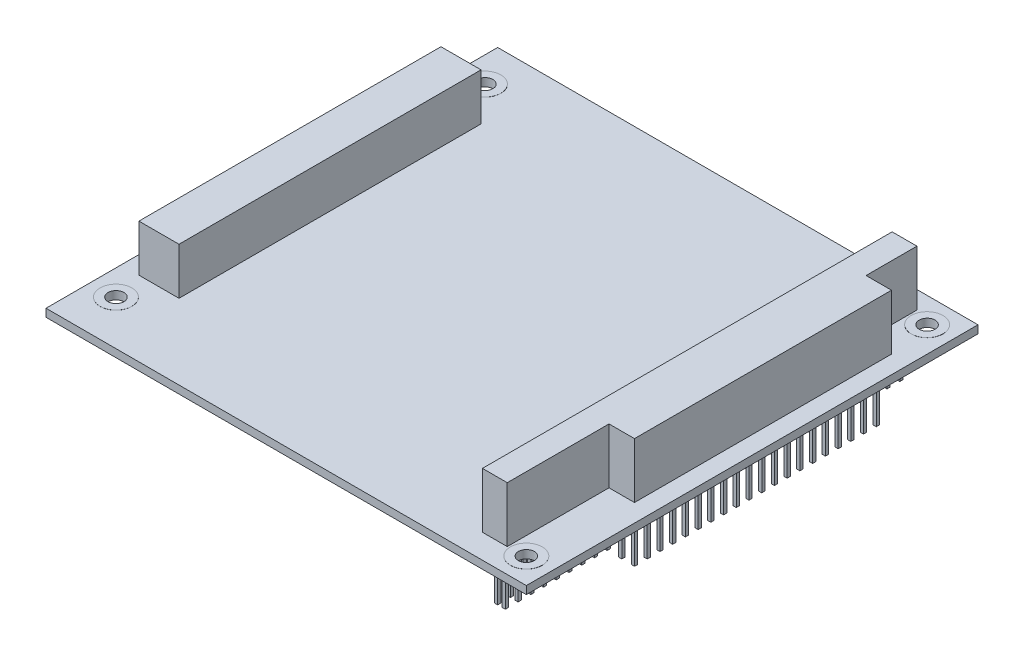
from build123d import *

# Parameters (mm, degrees)
SKETCH1_W                  = 95.89
SKETCH1_H                  = 90.17
BASE_EXTRUDE_DEPTH         = 1.57
SKETCH2_R                  = 1.59
MOUNTING_HOLES_DEPTH       = 66.831946272
SKETCH3_R                  = 3.175
SKETCH3_R_2                = 1.59
TOP_PADS_DEPTH             = 0.02
SKETCH4_R                  = 3.175
SKETCH4_R_2                = 1.59
BOTT_PADS_DEPTH            = 0.02
ISA_CNCT_DEPTH             = 11.05
SKETCH6_W                  = 8
SKETCH6_H                  = 60.3
PCI_CNCT_DEPTH             = 9.35
SKETCH7_W                  = 11.3
SKETCH7_H                  = 63.35
SKETCH7_W_2                = 8.51
SKETCH7_H_2                = 60.96
PCI_CNCT_SHROUD_DEPTH      = 11.18
SKETCH8_W                  = 0.64
SKETCH8_H                  = 0.64
BOT_ISA_DEPTH              = 10.67
LPATTERN1_COUNT            = 32
LPATTERN1_PITCH            = 2.54
SKETCH9_W                  = 0.64
SKETCH9_H                  = 0.64
BOSS_EXTRUDE7_DEPTH        = 10.67
LPATTERN2_COUNT            = 20
LPATTERN2_PITCH            = 2.54
SKETCH10_W                 = 0.5
SKETCH10_H                 = 0.5
PCI_BASE_DEPTH             = 10.41
LPATTERN3_COUNT            = 30
LPATTERN3_PITCH            = 2
LPATTERN4_COUNT            = 4
LPATTERN4_PITCH            = 2
LPATTERN4_COPY_1_SKETCH_W  = 0.5
LPATTERN4_COPY_1_SKETCH_H  = 0.5
LPATTERN4_COPY_1_DEPTH     = 10.41
LPATTERN4_COPY_2_SKETCH_W  = 0.5
LPATTERN4_COPY_2_SKETCH_H  = 0.5
LPATTERN4_COPY_2_DEPTH     = 10.41
LPATTERN4_COPY_3_SKETCH_W  = 0.5
LPATTERN4_COPY_3_SKETCH_H  = 0.5
LPATTERN4_COPY_3_DEPTH     = 10.41
LPATTERN4_COPY_4_SKETCH_W  = 0.5
LPATTERN4_COPY_4_SKETCH_H  = 0.5
LPATTERN4_COPY_4_DEPTH     = 10.41
LPATTERN4_COPY_5_SKETCH_W  = 0.5
LPATTERN4_COPY_5_SKETCH_H  = 0.5
LPATTERN4_COPY_5_DEPTH     = 10.41
LPATTERN4_COPY_6_SKETCH_W  = 0.5
LPATTERN4_COPY_6_SKETCH_H  = 0.5
LPATTERN4_COPY_6_DEPTH     = 10.41
LPATTERN4_COPY_7_SKETCH_W  = 0.5
LPATTERN4_COPY_7_SKETCH_H  = 0.5
LPATTERN4_COPY_7_DEPTH     = 10.41
LPATTERN4_COPY_8_SKETCH_W  = 0.5
LPATTERN4_COPY_8_SKETCH_H  = 0.5
LPATTERN4_COPY_8_DEPTH     = 10.41
LPATTERN4_COPY_9_SKETCH_W  = 0.5
LPATTERN4_COPY_9_SKETCH_H  = 0.5
LPATTERN4_COPY_9_DEPTH     = 10.41
LPATTERN4_COPY_10_SKETCH_W = 0.5
LPATTERN4_COPY_10_SKETCH_H = 0.5
LPATTERN4_COPY_10_DEPTH    = 10.41
LPATTERN4_COPY_11_SKETCH_W = 0.5
LPATTERN4_COPY_11_SKETCH_H = 0.5
LPATTERN4_COPY_11_DEPTH    = 10.41
LPATTERN4_COPY_12_SKETCH_W = 0.5
LPATTERN4_COPY_12_SKETCH_H = 0.5
LPATTERN4_COPY_12_DEPTH    = 10.41
LPATTERN4_COPY_13_SKETCH_W = 0.5
LPATTERN4_COPY_13_SKETCH_H = 0.5
LPATTERN4_COPY_13_DEPTH    = 10.41
LPATTERN4_COPY_14_SKETCH_W = 0.5
LPATTERN4_COPY_14_SKETCH_H = 0.5
LPATTERN4_COPY_14_DEPTH    = 10.41
LPATTERN4_COPY_15_SKETCH_W = 0.5
LPATTERN4_COPY_15_SKETCH_H = 0.5
LPATTERN4_COPY_15_DEPTH    = 10.41
LPATTERN4_COPY_16_SKETCH_W = 0.5
LPATTERN4_COPY_16_SKETCH_H = 0.5
LPATTERN4_COPY_16_DEPTH    = 10.41
LPATTERN4_COPY_17_SKETCH_W = 0.5
LPATTERN4_COPY_17_SKETCH_H = 0.5
LPATTERN4_COPY_17_DEPTH    = 10.41
LPATTERN4_COPY_18_SKETCH_W = 0.5
LPATTERN4_COPY_18_SKETCH_H = 0.5
LPATTERN4_COPY_18_DEPTH    = 10.41
LPATTERN4_COPY_19_SKETCH_W = 0.5
LPATTERN4_COPY_19_SKETCH_H = 0.5
LPATTERN4_COPY_19_DEPTH    = 10.41
LPATTERN4_COPY_20_SKETCH_W = 0.5
LPATTERN4_COPY_20_SKETCH_H = 0.5
LPATTERN4_COPY_20_DEPTH    = 10.41
LPATTERN4_COPY_21_SKETCH_W = 0.5
LPATTERN4_COPY_21_SKETCH_H = 0.5
LPATTERN4_COPY_21_DEPTH    = 10.41
LPATTERN4_COPY_22_SKETCH_W = 0.5
LPATTERN4_COPY_22_SKETCH_H = 0.5
LPATTERN4_COPY_22_DEPTH    = 10.41
LPATTERN4_COPY_23_SKETCH_W = 0.5
LPATTERN4_COPY_23_SKETCH_H = 0.5
LPATTERN4_COPY_23_DEPTH    = 10.41
LPATTERN4_COPY_24_SKETCH_W = 0.5
LPATTERN4_COPY_24_SKETCH_H = 0.5
LPATTERN4_COPY_24_DEPTH    = 10.41
LPATTERN4_COPY_25_SKETCH_W = 0.5
LPATTERN4_COPY_25_SKETCH_H = 0.5
LPATTERN4_COPY_25_DEPTH    = 10.41
LPATTERN4_COPY_26_SKETCH_W = 0.5
LPATTERN4_COPY_26_SKETCH_H = 0.5
LPATTERN4_COPY_26_DEPTH    = 10.41
LPATTERN4_COPY_27_SKETCH_W = 0.5
LPATTERN4_COPY_27_SKETCH_H = 0.5
LPATTERN4_COPY_27_DEPTH    = 10.41
LPATTERN4_COPY_28_SKETCH_W = 0.5
LPATTERN4_COPY_28_SKETCH_H = 0.5
LPATTERN4_COPY_28_DEPTH    = 10.41
LPATTERN4_COPY_29_SKETCH_W = 0.5
LPATTERN4_COPY_29_SKETCH_H = 0.5
LPATTERN4_COPY_29_DEPTH    = 10.41
LPATTERN4_COPY_30_SKETCH_W = 0.5
LPATTERN4_COPY_30_SKETCH_H = 0.5
LPATTERN4_COPY_30_DEPTH    = 10.41
LPATTERN4_COPY_31_SKETCH_W = 0.5
LPATTERN4_COPY_31_SKETCH_H = 0.5
LPATTERN4_COPY_31_DEPTH    = 10.41
LPATTERN4_COPY_32_SKETCH_W = 0.5
LPATTERN4_COPY_32_SKETCH_H = 0.5
LPATTERN4_COPY_32_DEPTH    = 10.41
LPATTERN4_COPY_33_SKETCH_W = 0.5
LPATTERN4_COPY_33_SKETCH_H = 0.5
LPATTERN4_COPY_33_DEPTH    = 10.41
LPATTERN4_COPY_34_SKETCH_W = 0.5
LPATTERN4_COPY_34_SKETCH_H = 0.5
LPATTERN4_COPY_34_DEPTH    = 10.41
LPATTERN4_COPY_35_SKETCH_W = 0.5
LPATTERN4_COPY_35_SKETCH_H = 0.5
LPATTERN4_COPY_35_DEPTH    = 10.41
LPATTERN4_COPY_36_SKETCH_W = 0.5
LPATTERN4_COPY_36_SKETCH_H = 0.5
LPATTERN4_COPY_36_DEPTH    = 10.41
LPATTERN4_COPY_37_SKETCH_W = 0.5
LPATTERN4_COPY_37_SKETCH_H = 0.5
LPATTERN4_COPY_37_DEPTH    = 10.41
LPATTERN4_COPY_38_SKETCH_W = 0.5
LPATTERN4_COPY_38_SKETCH_H = 0.5
LPATTERN4_COPY_38_DEPTH    = 10.41
LPATTERN4_COPY_39_SKETCH_W = 0.5
LPATTERN4_COPY_39_SKETCH_H = 0.5
LPATTERN4_COPY_39_DEPTH    = 10.41
LPATTERN4_COPY_40_SKETCH_W = 0.5
LPATTERN4_COPY_40_SKETCH_H = 0.5
LPATTERN4_COPY_40_DEPTH    = 10.41
LPATTERN4_COPY_41_SKETCH_W = 0.5
LPATTERN4_COPY_41_SKETCH_H = 0.5
LPATTERN4_COPY_41_DEPTH    = 10.41
LPATTERN4_COPY_42_SKETCH_W = 0.5
LPATTERN4_COPY_42_SKETCH_H = 0.5
LPATTERN4_COPY_42_DEPTH    = 10.41
LPATTERN4_COPY_43_SKETCH_W = 0.5
LPATTERN4_COPY_43_SKETCH_H = 0.5
LPATTERN4_COPY_43_DEPTH    = 10.41
LPATTERN4_COPY_44_SKETCH_W = 0.5
LPATTERN4_COPY_44_SKETCH_H = 0.5
LPATTERN4_COPY_44_DEPTH    = 10.41
LPATTERN4_COPY_45_SKETCH_W = 0.5
LPATTERN4_COPY_45_SKETCH_H = 0.5
LPATTERN4_COPY_45_DEPTH    = 10.41
LPATTERN4_COPY_46_SKETCH_W = 0.5
LPATTERN4_COPY_46_SKETCH_H = 0.5
LPATTERN4_COPY_46_DEPTH    = 10.41
LPATTERN4_COPY_47_SKETCH_W = 0.5
LPATTERN4_COPY_47_SKETCH_H = 0.5
LPATTERN4_COPY_47_DEPTH    = 10.41
LPATTERN4_COPY_48_SKETCH_W = 0.5
LPATTERN4_COPY_48_SKETCH_H = 0.5
LPATTERN4_COPY_48_DEPTH    = 10.41
LPATTERN4_COPY_49_SKETCH_W = 0.5
LPATTERN4_COPY_49_SKETCH_H = 0.5
LPATTERN4_COPY_49_DEPTH    = 10.41
LPATTERN4_COPY_50_SKETCH_W = 0.5
LPATTERN4_COPY_50_SKETCH_H = 0.5
LPATTERN4_COPY_50_DEPTH    = 10.41
LPATTERN4_COPY_51_SKETCH_W = 0.5
LPATTERN4_COPY_51_SKETCH_H = 0.5
LPATTERN4_COPY_51_DEPTH    = 10.41
LPATTERN4_COPY_52_SKETCH_W = 0.5
LPATTERN4_COPY_52_SKETCH_H = 0.5
LPATTERN4_COPY_52_DEPTH    = 10.41
LPATTERN4_COPY_53_SKETCH_W = 0.5
LPATTERN4_COPY_53_SKETCH_H = 0.5
LPATTERN4_COPY_53_DEPTH    = 10.41
LPATTERN4_COPY_54_SKETCH_W = 0.5
LPATTERN4_COPY_54_SKETCH_H = 0.5
LPATTERN4_COPY_54_DEPTH    = 10.41
LPATTERN4_COPY_55_SKETCH_W = 0.5
LPATTERN4_COPY_55_SKETCH_H = 0.5
LPATTERN4_COPY_55_DEPTH    = 10.41
LPATTERN4_COPY_56_SKETCH_W = 0.5
LPATTERN4_COPY_56_SKETCH_H = 0.5
LPATTERN4_COPY_56_DEPTH    = 10.41
LPATTERN4_COPY_57_SKETCH_W = 0.5
LPATTERN4_COPY_57_SKETCH_H = 0.5
LPATTERN4_COPY_57_DEPTH    = 10.41
LPATTERN4_COPY_58_SKETCH_W = 0.5
LPATTERN4_COPY_58_SKETCH_H = 0.5
LPATTERN4_COPY_58_DEPTH    = 10.41
LPATTERN4_COPY_59_SKETCH_W = 0.5
LPATTERN4_COPY_59_SKETCH_H = 0.5
LPATTERN4_COPY_59_DEPTH    = 10.41
LPATTERN4_COPY_60_SKETCH_W = 0.5
LPATTERN4_COPY_60_SKETCH_H = 0.5
LPATTERN4_COPY_60_DEPTH    = 10.41
LPATTERN4_COPY_61_SKETCH_W = 0.5
LPATTERN4_COPY_61_SKETCH_H = 0.5
LPATTERN4_COPY_61_DEPTH    = 10.41
LPATTERN4_COPY_62_SKETCH_W = 0.5
LPATTERN4_COPY_62_SKETCH_H = 0.5
LPATTERN4_COPY_62_DEPTH    = 10.41
LPATTERN4_COPY_63_SKETCH_W = 0.5
LPATTERN4_COPY_63_SKETCH_H = 0.5
LPATTERN4_COPY_63_DEPTH    = 10.41
LPATTERN4_COPY_64_SKETCH_W = 0.5
LPATTERN4_COPY_64_SKETCH_H = 0.5
LPATTERN4_COPY_64_DEPTH    = 10.41
LPATTERN4_COPY_65_SKETCH_W = 0.5
LPATTERN4_COPY_65_SKETCH_H = 0.5
LPATTERN4_COPY_65_DEPTH    = 10.41
LPATTERN4_COPY_66_SKETCH_W = 0.5
LPATTERN4_COPY_66_SKETCH_H = 0.5
LPATTERN4_COPY_66_DEPTH    = 10.41
LPATTERN4_COPY_67_SKETCH_W = 0.5
LPATTERN4_COPY_67_SKETCH_H = 0.5
LPATTERN4_COPY_67_DEPTH    = 10.41
LPATTERN4_COPY_68_SKETCH_W = 0.5
LPATTERN4_COPY_68_SKETCH_H = 0.5
LPATTERN4_COPY_68_DEPTH    = 10.41
LPATTERN4_COPY_69_SKETCH_W = 0.5
LPATTERN4_COPY_69_SKETCH_H = 0.5
LPATTERN4_COPY_69_DEPTH    = 10.41
LPATTERN4_COPY_70_SKETCH_W = 0.5
LPATTERN4_COPY_70_SKETCH_H = 0.5
LPATTERN4_COPY_70_DEPTH    = 10.41
LPATTERN4_COPY_71_SKETCH_W = 0.5
LPATTERN4_COPY_71_SKETCH_H = 0.5
LPATTERN4_COPY_71_DEPTH    = 10.41
LPATTERN4_COPY_72_SKETCH_W = 0.5
LPATTERN4_COPY_72_SKETCH_H = 0.5
LPATTERN4_COPY_72_DEPTH    = 10.41
LPATTERN4_COPY_73_SKETCH_W = 0.5
LPATTERN4_COPY_73_SKETCH_H = 0.5
LPATTERN4_COPY_73_DEPTH    = 10.41
LPATTERN4_COPY_74_SKETCH_W = 0.5
LPATTERN4_COPY_74_SKETCH_H = 0.5
LPATTERN4_COPY_74_DEPTH    = 10.41
LPATTERN4_COPY_75_SKETCH_W = 0.5
LPATTERN4_COPY_75_SKETCH_H = 0.5
LPATTERN4_COPY_75_DEPTH    = 10.41
LPATTERN4_COPY_76_SKETCH_W = 0.5
LPATTERN4_COPY_76_SKETCH_H = 0.5
LPATTERN4_COPY_76_DEPTH    = 10.41
LPATTERN4_COPY_77_SKETCH_W = 0.5
LPATTERN4_COPY_77_SKETCH_H = 0.5
LPATTERN4_COPY_77_DEPTH    = 10.41
LPATTERN4_COPY_78_SKETCH_W = 0.5
LPATTERN4_COPY_78_SKETCH_H = 0.5
LPATTERN4_COPY_78_DEPTH    = 10.41
LPATTERN4_COPY_79_SKETCH_W = 0.5
LPATTERN4_COPY_79_SKETCH_H = 0.5
LPATTERN4_COPY_79_DEPTH    = 10.41
LPATTERN4_COPY_80_SKETCH_W = 0.5
LPATTERN4_COPY_80_SKETCH_H = 0.5
LPATTERN4_COPY_80_DEPTH    = 10.41
LPATTERN4_COPY_81_SKETCH_W = 0.5
LPATTERN4_COPY_81_SKETCH_H = 0.5
LPATTERN4_COPY_81_DEPTH    = 10.41
LPATTERN4_COPY_82_SKETCH_W = 0.5
LPATTERN4_COPY_82_SKETCH_H = 0.5
LPATTERN4_COPY_82_DEPTH    = 10.41
LPATTERN4_COPY_83_SKETCH_W = 0.5
LPATTERN4_COPY_83_SKETCH_H = 0.5
LPATTERN4_COPY_83_DEPTH    = 10.41
LPATTERN4_COPY_84_SKETCH_W = 0.5
LPATTERN4_COPY_84_SKETCH_H = 0.5
LPATTERN4_COPY_84_DEPTH    = 10.41
LPATTERN4_COPY_85_SKETCH_W = 0.5
LPATTERN4_COPY_85_SKETCH_H = 0.5
LPATTERN4_COPY_85_DEPTH    = 10.41
LPATTERN4_COPY_86_SKETCH_W = 0.5
LPATTERN4_COPY_86_SKETCH_H = 0.5
LPATTERN4_COPY_86_DEPTH    = 10.41
LPATTERN4_COPY_87_SKETCH_W = 0.5
LPATTERN4_COPY_87_SKETCH_H = 0.5
LPATTERN4_COPY_87_DEPTH    = 10.41


with BuildPart() as part:
    # Sketch1 → Base-Extrude (new body)
    with BuildSketch(Plane(origin=(0, 0, 0), x_dir=(1, 0, 0), z_dir=(0, 1, 0))):
        Rectangle(SKETCH1_W, SKETCH1_H)
    extrude(amount=BASE_EXTRUDE_DEPTH)

    # Sketch2 → Mounting Holes (cut, through all)
    with BuildSketch(Plane(origin=(0, 1.57, 0), x_dir=(-1, 0, 0), z_dir=(0, 1, 0))):
        with Locations(Location((42.865, -37.465, 0), (0, 0, 90))):
            Circle(SKETCH2_R)
        with Locations(Location((42.865, 36.195, 0), (0, 0, 90))):
            Circle(SKETCH2_R)
        with Locations(Location((-42.865, 40.005, 0), (0, 0, 90))):
            Circle(SKETCH2_R)
        with Locations(Location((-42.865, -40.005, 0), (0, 0, 90))):
            Circle(SKETCH2_R)
    extrude(amount=-MOUNTING_HOLES_DEPTH, mode=Mode.SUBTRACT)

    # Sketch3 → Top Pads (add)
    with BuildSketch(Plane(origin=(0, 1.57, 0), x_dir=(-1, 0, 0), z_dir=(0, 1, 0))):
        with Locations(Location((42.865, -37.465, 0), (0, 0, 270))):
            Circle(SKETCH3_R)
        with Locations(Location((42.865, -37.465, 0), (0, 0, 90))):
            Circle(SKETCH3_R_2, mode=Mode.SUBTRACT)
        with Locations(Location((-42.865, -40.005, 0), (0, 0, 270))):
            Circle(SKETCH3_R)
        with Locations(Location((-42.865, -40.005, 0), (0, 0, 90))):
            Circle(SKETCH3_R_2, mode=Mode.SUBTRACT)
        with Locations(Location((-42.865, 40.005, 0), (0, 0, 270))):
            Circle(SKETCH3_R)
        with Locations(Location((-42.865, 40.005, 0), (0, 0, 90))):
            Circle(SKETCH3_R_2, mode=Mode.SUBTRACT)
        with Locations(Location((42.865, 36.195, 0), (0, 0, 270))):
            Circle(SKETCH3_R)
        with Locations(Location((42.865, 36.195, 0), (0, 0, 90))):
            Circle(SKETCH3_R_2, mode=Mode.SUBTRACT)
    extrude(amount=TOP_PADS_DEPTH)

    # Sketch4 → Bott Pads (add)
    with BuildSketch(Plane.XZ):
        with Locations(Location((-42.865, -37.465, 0), (0, 0, 270))):
            Circle(SKETCH4_R)
        with Locations(Location((-42.865, -37.465, 0), (0, 0, 90))):
            Circle(SKETCH4_R_2, mode=Mode.SUBTRACT)
        with Locations(Location((42.865, -40.005, 0), (0, 0, 270))):
            Circle(SKETCH4_R)
        with Locations(Location((42.865, -40.005, 0), (0, 0, 90))):
            Circle(SKETCH4_R_2, mode=Mode.SUBTRACT)
        with Locations(Location((42.865, 40.005, 0), (0, 0, 270))):
            Circle(SKETCH4_R)
        with Locations(Location((42.865, 40.005, 0), (0, 0, 90))):
            Circle(SKETCH4_R_2, mode=Mode.SUBTRACT)
        with Locations(Location((-42.865, 36.195, 0), (0, 0, 270))):
            Circle(SKETCH4_R)
        with Locations(Location((-42.865, 36.195, 0), (0, 0, 90))):
            Circle(SKETCH4_R_2, mode=Mode.SUBTRACT)
    extrude(amount=BOTT_PADS_DEPTH)

    # Sketch5 → ISA Cnct (add)
    with BuildSketch(Plane(origin=(0, 1.57, 0), x_dir=(-1, 0, 0), z_dir=(0, 1, 0))):
        Polygon((-39.305, 19.935), (-39.305, 40.255), (-34.355, 40.255), (-34.355, -41.535), (-39.305, -41.535), (-39.305, -31.375), (-44.385, -31.375), (-44.385, 19.935), align=None)
    extrude(amount=ISA_CNCT_DEPTH)

    # Sketch6 → PCI Cnct (add)
    with BuildSketch(Plane(origin=(0, 1.57, 0), x_dir=(-1, 0, 0), z_dir=(0, 1, 0))):
        with Locations((40.385, -0.055)):
            Rectangle(SKETCH6_W, SKETCH6_H)
    extrude(amount=PCI_CNCT_DEPTH)

    # Sketch7 → PCI Cnct Shroud (add)
    with BuildSketch(Plane.XZ):
        with Locations((-40.385, -0.055)):
            Rectangle(SKETCH7_W, SKETCH7_H)
        with Locations((-40.385, -0.055)):
            Rectangle(SKETCH7_W_2, SKETCH7_H_2, mode=Mode.SUBTRACT)
    extrude(amount=PCI_CNCT_SHROUD_DEPTH)

    # Sketch8 → Bot ISA (add)
    with BuildSketch(Plane.XZ):
        with Locations((35.875, -40.015)):
            Rectangle(SKETCH8_W, SKETCH8_H)
        with Locations((37.395, -40.015)):
            Rectangle(SKETCH8_W, SKETCH8_H)
    bot_isa = extrude(amount=BOT_ISA_DEPTH)

    # LPattern1: Bot ISA ×32
    with Locations(*[(0, 0, i * LPATTERN1_PITCH) for i in range(1, LPATTERN1_COUNT)]):
        add(bot_isa)

    # Sketch9 → Boss-Extrude7 (add)
    with BuildSketch(Plane.XZ):
        with Locations((40.325, -29.855)):
            Rectangle(SKETCH9_W, SKETCH9_H)
        with Locations((42.865, -29.855)):
            Rectangle(SKETCH9_W, SKETCH9_H)
    boss_extrude7 = extrude(amount=BOSS_EXTRUDE7_DEPTH)

    # LPattern2: Boss-Extrude7 ×20
    with Locations(*[(0, 0, i * LPATTERN2_PITCH) for i in range(1, LPATTERN2_COUNT)]):
        add(boss_extrude7)

    # Sketch10 → PCI Base (add)
    with BuildSketch(Plane.XZ):
        with Locations((-43.395, -28.535)):
            Rectangle(SKETCH10_W, SKETCH10_H)
    pci_base = extrude(amount=PCI_BASE_DEPTH)

    # LPattern3: PCI Base ×30
    with Locations(*[(0, 0, i * LPATTERN3_PITCH) for i in range(1, LPATTERN3_COUNT)]):
        add(pci_base)

    # LPattern4: PCI Base ×4
    with Locations(*[(i * LPATTERN4_PITCH, 0, 0) for i in range(1, LPATTERN4_COUNT)]):
        add(pci_base)

    # LPattern4 copy 1 sketch → LPattern4 copy 1 (add)
    with BuildSketch(Plane(origin=(2, 0, 2), x_dir=(1, 0, 0), z_dir=(0, -1, 0))):
        with Locations((-43.395, -28.535)):
            Rectangle(LPATTERN4_COPY_1_SKETCH_W, LPATTERN4_COPY_1_SKETCH_H)
    extrude(amount=LPATTERN4_COPY_1_DEPTH)

    # LPattern4 copy 2 sketch → LPattern4 copy 2 (add)
    with BuildSketch(Plane(origin=(4, 0, 2), x_dir=(1, 0, 0), z_dir=(0, -1, 0))):
        with Locations((-43.395, -28.535)):
            Rectangle(LPATTERN4_COPY_2_SKETCH_W, LPATTERN4_COPY_2_SKETCH_H)
    extrude(amount=LPATTERN4_COPY_2_DEPTH)

    # LPattern4 copy 3 sketch → LPattern4 copy 3 (add)
    with BuildSketch(Plane(origin=(6, 0, 2), x_dir=(1, 0, 0), z_dir=(0, -1, 0))):
        with Locations((-43.395, -28.535)):
            Rectangle(LPATTERN4_COPY_3_SKETCH_W, LPATTERN4_COPY_3_SKETCH_H)
    extrude(amount=LPATTERN4_COPY_3_DEPTH)

    # LPattern4 copy 4 sketch → LPattern4 copy 4 (add)
    with BuildSketch(Plane(origin=(2, 0, 4), x_dir=(1, 0, 0), z_dir=(0, -1, 0))):
        with Locations((-43.395, -28.535)):
            Rectangle(LPATTERN4_COPY_4_SKETCH_W, LPATTERN4_COPY_4_SKETCH_H)
    extrude(amount=LPATTERN4_COPY_4_DEPTH)

    # LPattern4 copy 5 sketch → LPattern4 copy 5 (add)
    with BuildSketch(Plane(origin=(4, 0, 4), x_dir=(1, 0, 0), z_dir=(0, -1, 0))):
        with Locations((-43.395, -28.535)):
            Rectangle(LPATTERN4_COPY_5_SKETCH_W, LPATTERN4_COPY_5_SKETCH_H)
    extrude(amount=LPATTERN4_COPY_5_DEPTH)

    # LPattern4 copy 6 sketch → LPattern4 copy 6 (add)
    with BuildSketch(Plane(origin=(6, 0, 4), x_dir=(1, 0, 0), z_dir=(0, -1, 0))):
        with Locations((-43.395, -28.535)):
            Rectangle(LPATTERN4_COPY_6_SKETCH_W, LPATTERN4_COPY_6_SKETCH_H)
    extrude(amount=LPATTERN4_COPY_6_DEPTH)

    # LPattern4 copy 7 sketch → LPattern4 copy 7 (add)
    with BuildSketch(Plane(origin=(2, 0, 6), x_dir=(1, 0, 0), z_dir=(0, -1, 0))):
        with Locations((-43.395, -28.535)):
            Rectangle(LPATTERN4_COPY_7_SKETCH_W, LPATTERN4_COPY_7_SKETCH_H)
    extrude(amount=LPATTERN4_COPY_7_DEPTH)

    # LPattern4 copy 8 sketch → LPattern4 copy 8 (add)
    with BuildSketch(Plane(origin=(4, 0, 6), x_dir=(1, 0, 0), z_dir=(0, -1, 0))):
        with Locations((-43.395, -28.535)):
            Rectangle(LPATTERN4_COPY_8_SKETCH_W, LPATTERN4_COPY_8_SKETCH_H)
    extrude(amount=LPATTERN4_COPY_8_DEPTH)

    # LPattern4 copy 9 sketch → LPattern4 copy 9 (add)
    with BuildSketch(Plane(origin=(6, 0, 6), x_dir=(1, 0, 0), z_dir=(0, -1, 0))):
        with Locations((-43.395, -28.535)):
            Rectangle(LPATTERN4_COPY_9_SKETCH_W, LPATTERN4_COPY_9_SKETCH_H)
    extrude(amount=LPATTERN4_COPY_9_DEPTH)

    # LPattern4 copy 10 sketch → LPattern4 copy 10 (add)
    with BuildSketch(Plane(origin=(2, 0, 8), x_dir=(1, 0, 0), z_dir=(0, -1, 0))):
        with Locations((-43.395, -28.535)):
            Rectangle(LPATTERN4_COPY_10_SKETCH_W, LPATTERN4_COPY_10_SKETCH_H)
    extrude(amount=LPATTERN4_COPY_10_DEPTH)

    # LPattern4 copy 11 sketch → LPattern4 copy 11 (add)
    with BuildSketch(Plane(origin=(4, 0, 8), x_dir=(1, 0, 0), z_dir=(0, -1, 0))):
        with Locations((-43.395, -28.535)):
            Rectangle(LPATTERN4_COPY_11_SKETCH_W, LPATTERN4_COPY_11_SKETCH_H)
    extrude(amount=LPATTERN4_COPY_11_DEPTH)

    # LPattern4 copy 12 sketch → LPattern4 copy 12 (add)
    with BuildSketch(Plane(origin=(6, 0, 8), x_dir=(1, 0, 0), z_dir=(0, -1, 0))):
        with Locations((-43.395, -28.535)):
            Rectangle(LPATTERN4_COPY_12_SKETCH_W, LPATTERN4_COPY_12_SKETCH_H)
    extrude(amount=LPATTERN4_COPY_12_DEPTH)

    # LPattern4 copy 13 sketch → LPattern4 copy 13 (add)
    with BuildSketch(Plane(origin=(2, 0, 10), x_dir=(1, 0, 0), z_dir=(0, -1, 0))):
        with Locations((-43.395, -28.535)):
            Rectangle(LPATTERN4_COPY_13_SKETCH_W, LPATTERN4_COPY_13_SKETCH_H)
    extrude(amount=LPATTERN4_COPY_13_DEPTH)

    # LPattern4 copy 14 sketch → LPattern4 copy 14 (add)
    with BuildSketch(Plane(origin=(4, 0, 10), x_dir=(1, 0, 0), z_dir=(0, -1, 0))):
        with Locations((-43.395, -28.535)):
            Rectangle(LPATTERN4_COPY_14_SKETCH_W, LPATTERN4_COPY_14_SKETCH_H)
    extrude(amount=LPATTERN4_COPY_14_DEPTH)

    # LPattern4 copy 15 sketch → LPattern4 copy 15 (add)
    with BuildSketch(Plane(origin=(6, 0, 10), x_dir=(1, 0, 0), z_dir=(0, -1, 0))):
        with Locations((-43.395, -28.535)):
            Rectangle(LPATTERN4_COPY_15_SKETCH_W, LPATTERN4_COPY_15_SKETCH_H)
    extrude(amount=LPATTERN4_COPY_15_DEPTH)

    # LPattern4 copy 16 sketch → LPattern4 copy 16 (add)
    with BuildSketch(Plane(origin=(2, 0, 12), x_dir=(1, 0, 0), z_dir=(0, -1, 0))):
        with Locations((-43.395, -28.535)):
            Rectangle(LPATTERN4_COPY_16_SKETCH_W, LPATTERN4_COPY_16_SKETCH_H)
    extrude(amount=LPATTERN4_COPY_16_DEPTH)

    # LPattern4 copy 17 sketch → LPattern4 copy 17 (add)
    with BuildSketch(Plane(origin=(4, 0, 12), x_dir=(1, 0, 0), z_dir=(0, -1, 0))):
        with Locations((-43.395, -28.535)):
            Rectangle(LPATTERN4_COPY_17_SKETCH_W, LPATTERN4_COPY_17_SKETCH_H)
    extrude(amount=LPATTERN4_COPY_17_DEPTH)

    # LPattern4 copy 18 sketch → LPattern4 copy 18 (add)
    with BuildSketch(Plane(origin=(6, 0, 12), x_dir=(1, 0, 0), z_dir=(0, -1, 0))):
        with Locations((-43.395, -28.535)):
            Rectangle(LPATTERN4_COPY_18_SKETCH_W, LPATTERN4_COPY_18_SKETCH_H)
    extrude(amount=LPATTERN4_COPY_18_DEPTH)

    # LPattern4 copy 19 sketch → LPattern4 copy 19 (add)
    with BuildSketch(Plane(origin=(2, 0, 14), x_dir=(1, 0, 0), z_dir=(0, -1, 0))):
        with Locations((-43.395, -28.535)):
            Rectangle(LPATTERN4_COPY_19_SKETCH_W, LPATTERN4_COPY_19_SKETCH_H)
    extrude(amount=LPATTERN4_COPY_19_DEPTH)

    # LPattern4 copy 20 sketch → LPattern4 copy 20 (add)
    with BuildSketch(Plane(origin=(4, 0, 14), x_dir=(1, 0, 0), z_dir=(0, -1, 0))):
        with Locations((-43.395, -28.535)):
            Rectangle(LPATTERN4_COPY_20_SKETCH_W, LPATTERN4_COPY_20_SKETCH_H)
    extrude(amount=LPATTERN4_COPY_20_DEPTH)

    # LPattern4 copy 21 sketch → LPattern4 copy 21 (add)
    with BuildSketch(Plane(origin=(6, 0, 14), x_dir=(1, 0, 0), z_dir=(0, -1, 0))):
        with Locations((-43.395, -28.535)):
            Rectangle(LPATTERN4_COPY_21_SKETCH_W, LPATTERN4_COPY_21_SKETCH_H)
    extrude(amount=LPATTERN4_COPY_21_DEPTH)

    # LPattern4 copy 22 sketch → LPattern4 copy 22 (add)
    with BuildSketch(Plane(origin=(2, 0, 16), x_dir=(1, 0, 0), z_dir=(0, -1, 0))):
        with Locations((-43.395, -28.535)):
            Rectangle(LPATTERN4_COPY_22_SKETCH_W, LPATTERN4_COPY_22_SKETCH_H)
    extrude(amount=LPATTERN4_COPY_22_DEPTH)

    # LPattern4 copy 23 sketch → LPattern4 copy 23 (add)
    with BuildSketch(Plane(origin=(4, 0, 16), x_dir=(1, 0, 0), z_dir=(0, -1, 0))):
        with Locations((-43.395, -28.535)):
            Rectangle(LPATTERN4_COPY_23_SKETCH_W, LPATTERN4_COPY_23_SKETCH_H)
    extrude(amount=LPATTERN4_COPY_23_DEPTH)

    # LPattern4 copy 24 sketch → LPattern4 copy 24 (add)
    with BuildSketch(Plane(origin=(6, 0, 16), x_dir=(1, 0, 0), z_dir=(0, -1, 0))):
        with Locations((-43.395, -28.535)):
            Rectangle(LPATTERN4_COPY_24_SKETCH_W, LPATTERN4_COPY_24_SKETCH_H)
    extrude(amount=LPATTERN4_COPY_24_DEPTH)

    # LPattern4 copy 25 sketch → LPattern4 copy 25 (add)
    with BuildSketch(Plane(origin=(2, 0, 18), x_dir=(1, 0, 0), z_dir=(0, -1, 0))):
        with Locations((-43.395, -28.535)):
            Rectangle(LPATTERN4_COPY_25_SKETCH_W, LPATTERN4_COPY_25_SKETCH_H)
    extrude(amount=LPATTERN4_COPY_25_DEPTH)

    # LPattern4 copy 26 sketch → LPattern4 copy 26 (add)
    with BuildSketch(Plane(origin=(4, 0, 18), x_dir=(1, 0, 0), z_dir=(0, -1, 0))):
        with Locations((-43.395, -28.535)):
            Rectangle(LPATTERN4_COPY_26_SKETCH_W, LPATTERN4_COPY_26_SKETCH_H)
    extrude(amount=LPATTERN4_COPY_26_DEPTH)

    # LPattern4 copy 27 sketch → LPattern4 copy 27 (add)
    with BuildSketch(Plane(origin=(6, 0, 18), x_dir=(1, 0, 0), z_dir=(0, -1, 0))):
        with Locations((-43.395, -28.535)):
            Rectangle(LPATTERN4_COPY_27_SKETCH_W, LPATTERN4_COPY_27_SKETCH_H)
    extrude(amount=LPATTERN4_COPY_27_DEPTH)

    # LPattern4 copy 28 sketch → LPattern4 copy 28 (add)
    with BuildSketch(Plane(origin=(2, 0, 20), x_dir=(1, 0, 0), z_dir=(0, -1, 0))):
        with Locations((-43.395, -28.535)):
            Rectangle(LPATTERN4_COPY_28_SKETCH_W, LPATTERN4_COPY_28_SKETCH_H)
    extrude(amount=LPATTERN4_COPY_28_DEPTH)

    # LPattern4 copy 29 sketch → LPattern4 copy 29 (add)
    with BuildSketch(Plane(origin=(4, 0, 20), x_dir=(1, 0, 0), z_dir=(0, -1, 0))):
        with Locations((-43.395, -28.535)):
            Rectangle(LPATTERN4_COPY_29_SKETCH_W, LPATTERN4_COPY_29_SKETCH_H)
    extrude(amount=LPATTERN4_COPY_29_DEPTH)

    # LPattern4 copy 30 sketch → LPattern4 copy 30 (add)
    with BuildSketch(Plane(origin=(6, 0, 20), x_dir=(1, 0, 0), z_dir=(0, -1, 0))):
        with Locations((-43.395, -28.535)):
            Rectangle(LPATTERN4_COPY_30_SKETCH_W, LPATTERN4_COPY_30_SKETCH_H)
    extrude(amount=LPATTERN4_COPY_30_DEPTH)

    # LPattern4 copy 31 sketch → LPattern4 copy 31 (add)
    with BuildSketch(Plane(origin=(2, 0, 22), x_dir=(1, 0, 0), z_dir=(0, -1, 0))):
        with Locations((-43.395, -28.535)):
            Rectangle(LPATTERN4_COPY_31_SKETCH_W, LPATTERN4_COPY_31_SKETCH_H)
    extrude(amount=LPATTERN4_COPY_31_DEPTH)

    # LPattern4 copy 32 sketch → LPattern4 copy 32 (add)
    with BuildSketch(Plane(origin=(4, 0, 22), x_dir=(1, 0, 0), z_dir=(0, -1, 0))):
        with Locations((-43.395, -28.535)):
            Rectangle(LPATTERN4_COPY_32_SKETCH_W, LPATTERN4_COPY_32_SKETCH_H)
    extrude(amount=LPATTERN4_COPY_32_DEPTH)

    # LPattern4 copy 33 sketch → LPattern4 copy 33 (add)
    with BuildSketch(Plane(origin=(6, 0, 22), x_dir=(1, 0, 0), z_dir=(0, -1, 0))):
        with Locations((-43.395, -28.535)):
            Rectangle(LPATTERN4_COPY_33_SKETCH_W, LPATTERN4_COPY_33_SKETCH_H)
    extrude(amount=LPATTERN4_COPY_33_DEPTH)

    # LPattern4 copy 34 sketch → LPattern4 copy 34 (add)
    with BuildSketch(Plane(origin=(2, 0, 24), x_dir=(1, 0, 0), z_dir=(0, -1, 0))):
        with Locations((-43.395, -28.535)):
            Rectangle(LPATTERN4_COPY_34_SKETCH_W, LPATTERN4_COPY_34_SKETCH_H)
    extrude(amount=LPATTERN4_COPY_34_DEPTH)

    # LPattern4 copy 35 sketch → LPattern4 copy 35 (add)
    with BuildSketch(Plane(origin=(4, 0, 24), x_dir=(1, 0, 0), z_dir=(0, -1, 0))):
        with Locations((-43.395, -28.535)):
            Rectangle(LPATTERN4_COPY_35_SKETCH_W, LPATTERN4_COPY_35_SKETCH_H)
    extrude(amount=LPATTERN4_COPY_35_DEPTH)

    # LPattern4 copy 36 sketch → LPattern4 copy 36 (add)
    with BuildSketch(Plane(origin=(6, 0, 24), x_dir=(1, 0, 0), z_dir=(0, -1, 0))):
        with Locations((-43.395, -28.535)):
            Rectangle(LPATTERN4_COPY_36_SKETCH_W, LPATTERN4_COPY_36_SKETCH_H)
    extrude(amount=LPATTERN4_COPY_36_DEPTH)

    # LPattern4 copy 37 sketch → LPattern4 copy 37 (add)
    with BuildSketch(Plane(origin=(2, 0, 26), x_dir=(1, 0, 0), z_dir=(0, -1, 0))):
        with Locations((-43.395, -28.535)):
            Rectangle(LPATTERN4_COPY_37_SKETCH_W, LPATTERN4_COPY_37_SKETCH_H)
    extrude(amount=LPATTERN4_COPY_37_DEPTH)

    # LPattern4 copy 38 sketch → LPattern4 copy 38 (add)
    with BuildSketch(Plane(origin=(4, 0, 26), x_dir=(1, 0, 0), z_dir=(0, -1, 0))):
        with Locations((-43.395, -28.535)):
            Rectangle(LPATTERN4_COPY_38_SKETCH_W, LPATTERN4_COPY_38_SKETCH_H)
    extrude(amount=LPATTERN4_COPY_38_DEPTH)

    # LPattern4 copy 39 sketch → LPattern4 copy 39 (add)
    with BuildSketch(Plane(origin=(6, 0, 26), x_dir=(1, 0, 0), z_dir=(0, -1, 0))):
        with Locations((-43.395, -28.535)):
            Rectangle(LPATTERN4_COPY_39_SKETCH_W, LPATTERN4_COPY_39_SKETCH_H)
    extrude(amount=LPATTERN4_COPY_39_DEPTH)

    # LPattern4 copy 40 sketch → LPattern4 copy 40 (add)
    with BuildSketch(Plane(origin=(2, 0, 28), x_dir=(1, 0, 0), z_dir=(0, -1, 0))):
        with Locations((-43.395, -28.535)):
            Rectangle(LPATTERN4_COPY_40_SKETCH_W, LPATTERN4_COPY_40_SKETCH_H)
    extrude(amount=LPATTERN4_COPY_40_DEPTH)

    # LPattern4 copy 41 sketch → LPattern4 copy 41 (add)
    with BuildSketch(Plane(origin=(4, 0, 28), x_dir=(1, 0, 0), z_dir=(0, -1, 0))):
        with Locations((-43.395, -28.535)):
            Rectangle(LPATTERN4_COPY_41_SKETCH_W, LPATTERN4_COPY_41_SKETCH_H)
    extrude(amount=LPATTERN4_COPY_41_DEPTH)

    # LPattern4 copy 42 sketch → LPattern4 copy 42 (add)
    with BuildSketch(Plane(origin=(6, 0, 28), x_dir=(1, 0, 0), z_dir=(0, -1, 0))):
        with Locations((-43.395, -28.535)):
            Rectangle(LPATTERN4_COPY_42_SKETCH_W, LPATTERN4_COPY_42_SKETCH_H)
    extrude(amount=LPATTERN4_COPY_42_DEPTH)

    # LPattern4 copy 43 sketch → LPattern4 copy 43 (add)
    with BuildSketch(Plane(origin=(2, 0, 30), x_dir=(1, 0, 0), z_dir=(0, -1, 0))):
        with Locations((-43.395, -28.535)):
            Rectangle(LPATTERN4_COPY_43_SKETCH_W, LPATTERN4_COPY_43_SKETCH_H)
    extrude(amount=LPATTERN4_COPY_43_DEPTH)

    # LPattern4 copy 44 sketch → LPattern4 copy 44 (add)
    with BuildSketch(Plane(origin=(4, 0, 30), x_dir=(1, 0, 0), z_dir=(0, -1, 0))):
        with Locations((-43.395, -28.535)):
            Rectangle(LPATTERN4_COPY_44_SKETCH_W, LPATTERN4_COPY_44_SKETCH_H)
    extrude(amount=LPATTERN4_COPY_44_DEPTH)

    # LPattern4 copy 45 sketch → LPattern4 copy 45 (add)
    with BuildSketch(Plane(origin=(6, 0, 30), x_dir=(1, 0, 0), z_dir=(0, -1, 0))):
        with Locations((-43.395, -28.535)):
            Rectangle(LPATTERN4_COPY_45_SKETCH_W, LPATTERN4_COPY_45_SKETCH_H)
    extrude(amount=LPATTERN4_COPY_45_DEPTH)

    # LPattern4 copy 46 sketch → LPattern4 copy 46 (add)
    with BuildSketch(Plane(origin=(2, 0, 32), x_dir=(1, 0, 0), z_dir=(0, -1, 0))):
        with Locations((-43.395, -28.535)):
            Rectangle(LPATTERN4_COPY_46_SKETCH_W, LPATTERN4_COPY_46_SKETCH_H)
    extrude(amount=LPATTERN4_COPY_46_DEPTH)

    # LPattern4 copy 47 sketch → LPattern4 copy 47 (add)
    with BuildSketch(Plane(origin=(4, 0, 32), x_dir=(1, 0, 0), z_dir=(0, -1, 0))):
        with Locations((-43.395, -28.535)):
            Rectangle(LPATTERN4_COPY_47_SKETCH_W, LPATTERN4_COPY_47_SKETCH_H)
    extrude(amount=LPATTERN4_COPY_47_DEPTH)

    # LPattern4 copy 48 sketch → LPattern4 copy 48 (add)
    with BuildSketch(Plane(origin=(6, 0, 32), x_dir=(1, 0, 0), z_dir=(0, -1, 0))):
        with Locations((-43.395, -28.535)):
            Rectangle(LPATTERN4_COPY_48_SKETCH_W, LPATTERN4_COPY_48_SKETCH_H)
    extrude(amount=LPATTERN4_COPY_48_DEPTH)

    # LPattern4 copy 49 sketch → LPattern4 copy 49 (add)
    with BuildSketch(Plane(origin=(2, 0, 34), x_dir=(1, 0, 0), z_dir=(0, -1, 0))):
        with Locations((-43.395, -28.535)):
            Rectangle(LPATTERN4_COPY_49_SKETCH_W, LPATTERN4_COPY_49_SKETCH_H)
    extrude(amount=LPATTERN4_COPY_49_DEPTH)

    # LPattern4 copy 50 sketch → LPattern4 copy 50 (add)
    with BuildSketch(Plane(origin=(4, 0, 34), x_dir=(1, 0, 0), z_dir=(0, -1, 0))):
        with Locations((-43.395, -28.535)):
            Rectangle(LPATTERN4_COPY_50_SKETCH_W, LPATTERN4_COPY_50_SKETCH_H)
    extrude(amount=LPATTERN4_COPY_50_DEPTH)

    # LPattern4 copy 51 sketch → LPattern4 copy 51 (add)
    with BuildSketch(Plane(origin=(6, 0, 34), x_dir=(1, 0, 0), z_dir=(0, -1, 0))):
        with Locations((-43.395, -28.535)):
            Rectangle(LPATTERN4_COPY_51_SKETCH_W, LPATTERN4_COPY_51_SKETCH_H)
    extrude(amount=LPATTERN4_COPY_51_DEPTH)

    # LPattern4 copy 52 sketch → LPattern4 copy 52 (add)
    with BuildSketch(Plane(origin=(2, 0, 36), x_dir=(1, 0, 0), z_dir=(0, -1, 0))):
        with Locations((-43.395, -28.535)):
            Rectangle(LPATTERN4_COPY_52_SKETCH_W, LPATTERN4_COPY_52_SKETCH_H)
    extrude(amount=LPATTERN4_COPY_52_DEPTH)

    # LPattern4 copy 53 sketch → LPattern4 copy 53 (add)
    with BuildSketch(Plane(origin=(4, 0, 36), x_dir=(1, 0, 0), z_dir=(0, -1, 0))):
        with Locations((-43.395, -28.535)):
            Rectangle(LPATTERN4_COPY_53_SKETCH_W, LPATTERN4_COPY_53_SKETCH_H)
    extrude(amount=LPATTERN4_COPY_53_DEPTH)

    # LPattern4 copy 54 sketch → LPattern4 copy 54 (add)
    with BuildSketch(Plane(origin=(6, 0, 36), x_dir=(1, 0, 0), z_dir=(0, -1, 0))):
        with Locations((-43.395, -28.535)):
            Rectangle(LPATTERN4_COPY_54_SKETCH_W, LPATTERN4_COPY_54_SKETCH_H)
    extrude(amount=LPATTERN4_COPY_54_DEPTH)

    # LPattern4 copy 55 sketch → LPattern4 copy 55 (add)
    with BuildSketch(Plane(origin=(2, 0, 38), x_dir=(1, 0, 0), z_dir=(0, -1, 0))):
        with Locations((-43.395, -28.535)):
            Rectangle(LPATTERN4_COPY_55_SKETCH_W, LPATTERN4_COPY_55_SKETCH_H)
    extrude(amount=LPATTERN4_COPY_55_DEPTH)

    # LPattern4 copy 56 sketch → LPattern4 copy 56 (add)
    with BuildSketch(Plane(origin=(4, 0, 38), x_dir=(1, 0, 0), z_dir=(0, -1, 0))):
        with Locations((-43.395, -28.535)):
            Rectangle(LPATTERN4_COPY_56_SKETCH_W, LPATTERN4_COPY_56_SKETCH_H)
    extrude(amount=LPATTERN4_COPY_56_DEPTH)

    # LPattern4 copy 57 sketch → LPattern4 copy 57 (add)
    with BuildSketch(Plane(origin=(6, 0, 38), x_dir=(1, 0, 0), z_dir=(0, -1, 0))):
        with Locations((-43.395, -28.535)):
            Rectangle(LPATTERN4_COPY_57_SKETCH_W, LPATTERN4_COPY_57_SKETCH_H)
    extrude(amount=LPATTERN4_COPY_57_DEPTH)

    # LPattern4 copy 58 sketch → LPattern4 copy 58 (add)
    with BuildSketch(Plane(origin=(2, 0, 40), x_dir=(1, 0, 0), z_dir=(0, -1, 0))):
        with Locations((-43.395, -28.535)):
            Rectangle(LPATTERN4_COPY_58_SKETCH_W, LPATTERN4_COPY_58_SKETCH_H)
    extrude(amount=LPATTERN4_COPY_58_DEPTH)

    # LPattern4 copy 59 sketch → LPattern4 copy 59 (add)
    with BuildSketch(Plane(origin=(4, 0, 40), x_dir=(1, 0, 0), z_dir=(0, -1, 0))):
        with Locations((-43.395, -28.535)):
            Rectangle(LPATTERN4_COPY_59_SKETCH_W, LPATTERN4_COPY_59_SKETCH_H)
    extrude(amount=LPATTERN4_COPY_59_DEPTH)

    # LPattern4 copy 60 sketch → LPattern4 copy 60 (add)
    with BuildSketch(Plane(origin=(6, 0, 40), x_dir=(1, 0, 0), z_dir=(0, -1, 0))):
        with Locations((-43.395, -28.535)):
            Rectangle(LPATTERN4_COPY_60_SKETCH_W, LPATTERN4_COPY_60_SKETCH_H)
    extrude(amount=LPATTERN4_COPY_60_DEPTH)

    # LPattern4 copy 61 sketch → LPattern4 copy 61 (add)
    with BuildSketch(Plane(origin=(2, 0, 42), x_dir=(1, 0, 0), z_dir=(0, -1, 0))):
        with Locations((-43.395, -28.535)):
            Rectangle(LPATTERN4_COPY_61_SKETCH_W, LPATTERN4_COPY_61_SKETCH_H)
    extrude(amount=LPATTERN4_COPY_61_DEPTH)

    # LPattern4 copy 62 sketch → LPattern4 copy 62 (add)
    with BuildSketch(Plane(origin=(4, 0, 42), x_dir=(1, 0, 0), z_dir=(0, -1, 0))):
        with Locations((-43.395, -28.535)):
            Rectangle(LPATTERN4_COPY_62_SKETCH_W, LPATTERN4_COPY_62_SKETCH_H)
    extrude(amount=LPATTERN4_COPY_62_DEPTH)

    # LPattern4 copy 63 sketch → LPattern4 copy 63 (add)
    with BuildSketch(Plane(origin=(6, 0, 42), x_dir=(1, 0, 0), z_dir=(0, -1, 0))):
        with Locations((-43.395, -28.535)):
            Rectangle(LPATTERN4_COPY_63_SKETCH_W, LPATTERN4_COPY_63_SKETCH_H)
    extrude(amount=LPATTERN4_COPY_63_DEPTH)

    # LPattern4 copy 64 sketch → LPattern4 copy 64 (add)
    with BuildSketch(Plane(origin=(2, 0, 44), x_dir=(1, 0, 0), z_dir=(0, -1, 0))):
        with Locations((-43.395, -28.535)):
            Rectangle(LPATTERN4_COPY_64_SKETCH_W, LPATTERN4_COPY_64_SKETCH_H)
    extrude(amount=LPATTERN4_COPY_64_DEPTH)

    # LPattern4 copy 65 sketch → LPattern4 copy 65 (add)
    with BuildSketch(Plane(origin=(4, 0, 44), x_dir=(1, 0, 0), z_dir=(0, -1, 0))):
        with Locations((-43.395, -28.535)):
            Rectangle(LPATTERN4_COPY_65_SKETCH_W, LPATTERN4_COPY_65_SKETCH_H)
    extrude(amount=LPATTERN4_COPY_65_DEPTH)

    # LPattern4 copy 66 sketch → LPattern4 copy 66 (add)
    with BuildSketch(Plane(origin=(6, 0, 44), x_dir=(1, 0, 0), z_dir=(0, -1, 0))):
        with Locations((-43.395, -28.535)):
            Rectangle(LPATTERN4_COPY_66_SKETCH_W, LPATTERN4_COPY_66_SKETCH_H)
    extrude(amount=LPATTERN4_COPY_66_DEPTH)

    # LPattern4 copy 67 sketch → LPattern4 copy 67 (add)
    with BuildSketch(Plane(origin=(2, 0, 46), x_dir=(1, 0, 0), z_dir=(0, -1, 0))):
        with Locations((-43.395, -28.535)):
            Rectangle(LPATTERN4_COPY_67_SKETCH_W, LPATTERN4_COPY_67_SKETCH_H)
    extrude(amount=LPATTERN4_COPY_67_DEPTH)

    # LPattern4 copy 68 sketch → LPattern4 copy 68 (add)
    with BuildSketch(Plane(origin=(4, 0, 46), x_dir=(1, 0, 0), z_dir=(0, -1, 0))):
        with Locations((-43.395, -28.535)):
            Rectangle(LPATTERN4_COPY_68_SKETCH_W, LPATTERN4_COPY_68_SKETCH_H)
    extrude(amount=LPATTERN4_COPY_68_DEPTH)

    # LPattern4 copy 69 sketch → LPattern4 copy 69 (add)
    with BuildSketch(Plane(origin=(6, 0, 46), x_dir=(1, 0, 0), z_dir=(0, -1, 0))):
        with Locations((-43.395, -28.535)):
            Rectangle(LPATTERN4_COPY_69_SKETCH_W, LPATTERN4_COPY_69_SKETCH_H)
    extrude(amount=LPATTERN4_COPY_69_DEPTH)

    # LPattern4 copy 70 sketch → LPattern4 copy 70 (add)
    with BuildSketch(Plane(origin=(2, 0, 48), x_dir=(1, 0, 0), z_dir=(0, -1, 0))):
        with Locations((-43.395, -28.535)):
            Rectangle(LPATTERN4_COPY_70_SKETCH_W, LPATTERN4_COPY_70_SKETCH_H)
    extrude(amount=LPATTERN4_COPY_70_DEPTH)

    # LPattern4 copy 71 sketch → LPattern4 copy 71 (add)
    with BuildSketch(Plane(origin=(4, 0, 48), x_dir=(1, 0, 0), z_dir=(0, -1, 0))):
        with Locations((-43.395, -28.535)):
            Rectangle(LPATTERN4_COPY_71_SKETCH_W, LPATTERN4_COPY_71_SKETCH_H)
    extrude(amount=LPATTERN4_COPY_71_DEPTH)

    # LPattern4 copy 72 sketch → LPattern4 copy 72 (add)
    with BuildSketch(Plane(origin=(6, 0, 48), x_dir=(1, 0, 0), z_dir=(0, -1, 0))):
        with Locations((-43.395, -28.535)):
            Rectangle(LPATTERN4_COPY_72_SKETCH_W, LPATTERN4_COPY_72_SKETCH_H)
    extrude(amount=LPATTERN4_COPY_72_DEPTH)

    # LPattern4 copy 73 sketch → LPattern4 copy 73 (add)
    with BuildSketch(Plane(origin=(2, 0, 50), x_dir=(1, 0, 0), z_dir=(0, -1, 0))):
        with Locations((-43.395, -28.535)):
            Rectangle(LPATTERN4_COPY_73_SKETCH_W, LPATTERN4_COPY_73_SKETCH_H)
    extrude(amount=LPATTERN4_COPY_73_DEPTH)

    # LPattern4 copy 74 sketch → LPattern4 copy 74 (add)
    with BuildSketch(Plane(origin=(4, 0, 50), x_dir=(1, 0, 0), z_dir=(0, -1, 0))):
        with Locations((-43.395, -28.535)):
            Rectangle(LPATTERN4_COPY_74_SKETCH_W, LPATTERN4_COPY_74_SKETCH_H)
    extrude(amount=LPATTERN4_COPY_74_DEPTH)

    # LPattern4 copy 75 sketch → LPattern4 copy 75 (add)
    with BuildSketch(Plane(origin=(6, 0, 50), x_dir=(1, 0, 0), z_dir=(0, -1, 0))):
        with Locations((-43.395, -28.535)):
            Rectangle(LPATTERN4_COPY_75_SKETCH_W, LPATTERN4_COPY_75_SKETCH_H)
    extrude(amount=LPATTERN4_COPY_75_DEPTH)

    # LPattern4 copy 76 sketch → LPattern4 copy 76 (add)
    with BuildSketch(Plane(origin=(2, 0, 52), x_dir=(1, 0, 0), z_dir=(0, -1, 0))):
        with Locations((-43.395, -28.535)):
            Rectangle(LPATTERN4_COPY_76_SKETCH_W, LPATTERN4_COPY_76_SKETCH_H)
    extrude(amount=LPATTERN4_COPY_76_DEPTH)

    # LPattern4 copy 77 sketch → LPattern4 copy 77 (add)
    with BuildSketch(Plane(origin=(4, 0, 52), x_dir=(1, 0, 0), z_dir=(0, -1, 0))):
        with Locations((-43.395, -28.535)):
            Rectangle(LPATTERN4_COPY_77_SKETCH_W, LPATTERN4_COPY_77_SKETCH_H)
    extrude(amount=LPATTERN4_COPY_77_DEPTH)

    # LPattern4 copy 78 sketch → LPattern4 copy 78 (add)
    with BuildSketch(Plane(origin=(6, 0, 52), x_dir=(1, 0, 0), z_dir=(0, -1, 0))):
        with Locations((-43.395, -28.535)):
            Rectangle(LPATTERN4_COPY_78_SKETCH_W, LPATTERN4_COPY_78_SKETCH_H)
    extrude(amount=LPATTERN4_COPY_78_DEPTH)

    # LPattern4 copy 79 sketch → LPattern4 copy 79 (add)
    with BuildSketch(Plane(origin=(2, 0, 54), x_dir=(1, 0, 0), z_dir=(0, -1, 0))):
        with Locations((-43.395, -28.535)):
            Rectangle(LPATTERN4_COPY_79_SKETCH_W, LPATTERN4_COPY_79_SKETCH_H)
    extrude(amount=LPATTERN4_COPY_79_DEPTH)

    # LPattern4 copy 80 sketch → LPattern4 copy 80 (add)
    with BuildSketch(Plane(origin=(4, 0, 54), x_dir=(1, 0, 0), z_dir=(0, -1, 0))):
        with Locations((-43.395, -28.535)):
            Rectangle(LPATTERN4_COPY_80_SKETCH_W, LPATTERN4_COPY_80_SKETCH_H)
    extrude(amount=LPATTERN4_COPY_80_DEPTH)

    # LPattern4 copy 81 sketch → LPattern4 copy 81 (add)
    with BuildSketch(Plane(origin=(6, 0, 54), x_dir=(1, 0, 0), z_dir=(0, -1, 0))):
        with Locations((-43.395, -28.535)):
            Rectangle(LPATTERN4_COPY_81_SKETCH_W, LPATTERN4_COPY_81_SKETCH_H)
    extrude(amount=LPATTERN4_COPY_81_DEPTH)

    # LPattern4 copy 82 sketch → LPattern4 copy 82 (add)
    with BuildSketch(Plane(origin=(2, 0, 56), x_dir=(1, 0, 0), z_dir=(0, -1, 0))):
        with Locations((-43.395, -28.535)):
            Rectangle(LPATTERN4_COPY_82_SKETCH_W, LPATTERN4_COPY_82_SKETCH_H)
    extrude(amount=LPATTERN4_COPY_82_DEPTH)

    # LPattern4 copy 83 sketch → LPattern4 copy 83 (add)
    with BuildSketch(Plane(origin=(4, 0, 56), x_dir=(1, 0, 0), z_dir=(0, -1, 0))):
        with Locations((-43.395, -28.535)):
            Rectangle(LPATTERN4_COPY_83_SKETCH_W, LPATTERN4_COPY_83_SKETCH_H)
    extrude(amount=LPATTERN4_COPY_83_DEPTH)

    # LPattern4 copy 84 sketch → LPattern4 copy 84 (add)
    with BuildSketch(Plane(origin=(6, 0, 56), x_dir=(1, 0, 0), z_dir=(0, -1, 0))):
        with Locations((-43.395, -28.535)):
            Rectangle(LPATTERN4_COPY_84_SKETCH_W, LPATTERN4_COPY_84_SKETCH_H)
    extrude(amount=LPATTERN4_COPY_84_DEPTH)

    # LPattern4 copy 85 sketch → LPattern4 copy 85 (add)
    with BuildSketch(Plane(origin=(2, 0, 58), x_dir=(1, 0, 0), z_dir=(0, -1, 0))):
        with Locations((-43.395, -28.535)):
            Rectangle(LPATTERN4_COPY_85_SKETCH_W, LPATTERN4_COPY_85_SKETCH_H)
    extrude(amount=LPATTERN4_COPY_85_DEPTH)

    # LPattern4 copy 86 sketch → LPattern4 copy 86 (add)
    with BuildSketch(Plane(origin=(4, 0, 58), x_dir=(1, 0, 0), z_dir=(0, -1, 0))):
        with Locations((-43.395, -28.535)):
            Rectangle(LPATTERN4_COPY_86_SKETCH_W, LPATTERN4_COPY_86_SKETCH_H)
    extrude(amount=LPATTERN4_COPY_86_DEPTH)

    # LPattern4 copy 87 sketch → LPattern4 copy 87 (add)
    with BuildSketch(Plane(origin=(6, 0, 58), x_dir=(1, 0, 0), z_dir=(0, -1, 0))):
        with Locations((-43.395, -28.535)):
            Rectangle(LPATTERN4_COPY_87_SKETCH_W, LPATTERN4_COPY_87_SKETCH_H)
    extrude(amount=LPATTERN4_COPY_87_DEPTH)


solid = part.part
